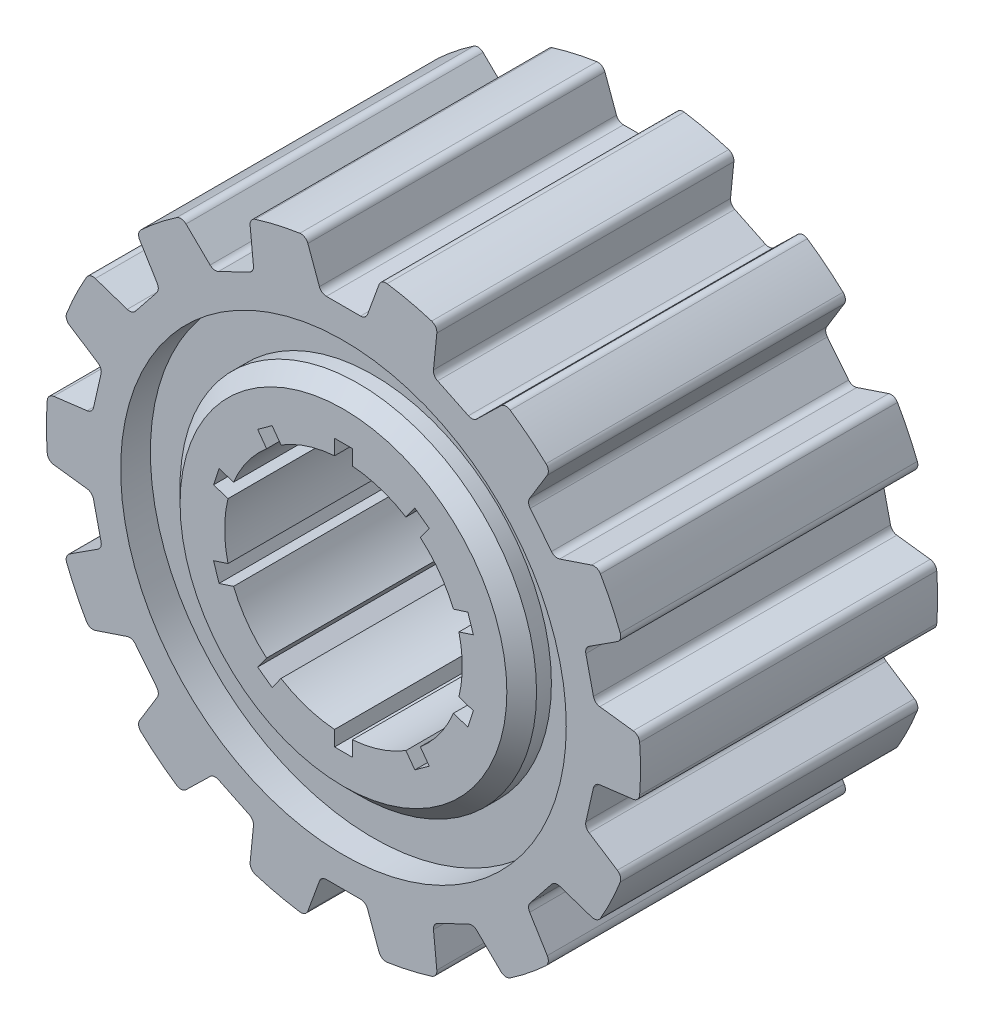
from build123d import *

# Parameters (mm, degrees)
SKETCH1_R           = 10
BOSS_EXTRUDE1_DEPTH = 10
CUT_EXTRUDE1_DEPTH  = 11
CIRPATTERN1_COUNT   = 14
CUT_EXTRUDE2_START  = -4
SKETCH3_R           = 7.5
SKETCH3_R_2         = 6
CUT_EXTRUDE2_DEPTH  = 2
CHAMFER1_SIZE       = 0.5
CHAMFER2_SIZE       = 0.5
FILLET1_R           = 0.25


with BuildPart() as part:
    # Sketch1 → Boss-Extrude1 (new body)
    with BuildSketch(Plane.XY):
        Circle(SKETCH1_R)
        with BuildLine():
            Line((2.402328537, 3.81691205), (2.887738734, 3.464240899))
            Line((2.887738734, 3.464240899), (2.587224198, 3.050618126))
            ThreePointArc((2.587224198, 3.050618126), (3.236067977, 2.351141009), (3.700806493, 1.517903589))
            Line((3.700806493, 1.517903589), (4.187049225, 1.67589343))
            Line((4.187049225, 1.67589343), (4.372459422, 1.10525952))
            Line((4.372459422, 1.10525952), (3.886216689, 0.947269679))
            ThreePointArc((3.886216689, 0.947269679), (4, 0), (3.886216689, -0.947269679))
            Line((3.886216689, -0.947269679), (4.372459422, -1.10525952))
            Line((4.372459422, -1.10525952), (4.187049225, -1.67589343))
            Line((4.187049225, -1.67589343), (3.700806493, -1.517903589))
            ThreePointArc((3.700806493, -1.517903589), (3.236067977, -2.351141009), (2.587224198, -3.050618126))
            Line((2.587224198, -3.050618126), (2.887738734, -3.464240899))
            Line((2.887738734, -3.464240899), (2.402328537, -3.81691205))
            Line((2.402328537, -3.81691205), (2.101814002, -3.403289277))
            ThreePointArc((2.101814002, -3.403289277), (1.236067977, -3.804226065), (0.3, -3.988734135))
            Line((0.3, -3.988734135), (0.3, -4.5))
            Line((0.3, -4.5), (-0.3, -4.5))
            Line((-0.3, -4.5), (-0.3, -3.988734135))
            ThreePointArc((-0.3, -3.988734135), (-1.236067977, -3.804226065), (-2.101814002, -3.403289277))
            Line((-2.101814002, -3.403289277), (-2.402328537, -3.81691205))
            Line((-2.402328537, -3.81691205), (-2.887738734, -3.464240899))
            Line((-2.887738734, -3.464240899), (-2.587224198, -3.050618126))
            ThreePointArc((-2.587224198, -3.050618126), (-3.236067977, -2.351141009), (-3.700806493, -1.517903589))
            Line((-3.700806493, -1.517903589), (-4.187049225, -1.67589343))
            Line((-4.187049225, -1.67589343), (-4.372459422, -1.10525952))
            Line((-4.372459422, -1.10525952), (-3.886216689, -0.947269679))
            ThreePointArc((-3.886216689, -0.947269679), (-4, 0), (-3.886216689, 0.947269679))
            Line((-3.886216689, 0.947269679), (-4.372459422, 1.10525952))
            Line((-4.372459422, 1.10525952), (-4.187049225, 1.67589343))
            Line((-4.187049225, 1.67589343), (-3.700806493, 1.517903589))
            ThreePointArc((-3.700806493, 1.517903589), (-3.236067977, 2.351141009), (-2.587224198, 3.050618126))
            Line((-2.587224198, 3.050618126), (-2.887738734, 3.464240899))
            Line((-2.887738734, 3.464240899), (-2.402328537, 3.81691205))
            Line((-2.402328537, 3.81691205), (-2.101814002, 3.403289277))
            ThreePointArc((-2.101814002, 3.403289277), (-1.236067977, 3.804226065), (-0.3, 3.988734135))
            Line((-0.3, 3.988734135), (-0.3, 4.5))
            Line((-0.3, 4.5), (0.3, 4.5))
            Line((0.3, 4.5), (0.3, 3.988734135))
            ThreePointArc((0.3, 3.988734135), (1.236067977, 3.804226065), (2.101814002, 3.403289277))
            Line((2.101814002, 3.403289277), (2.402328537, 3.81691205))
        make_face(mode=Mode.SUBTRACT)
    extrude(amount=BOSS_EXTRUDE1_DEPTH)

    # Sketch2 → Cut-Extrude1 (cut, through all)
    with BuildSketch(Plane.XY.offset(10)):
        Polygon((-20.341084154, 62.326061337), (-1.266640021, 9.919456792), (-0.75, 8.5), (0.75, 8.5), (1.266640021, 9.919456792), (20.341084154, 62.326061337), (20.341084154, 173.86594871), (-20.341084154, 173.86594871), align=None)
    cut_extrude1 = extrude(amount=-CUT_EXTRUDE1_DEPTH, mode=Mode.SUBTRACT)

    # CirPattern1: Cut-Extrude1 ×14 about axis
    cirpattern1_axis = Axis((0, 0, 0), (0, 0, 1))
    for i in range(1, CIRPATTERN1_COUNT):
        add(cut_extrude1.rotate(cirpattern1_axis, i * 360 / CIRPATTERN1_COUNT), mode=Mode.SUBTRACT)

    # Sketch3 → Cut-Extrude2 (cut, through all)
    with BuildSketch(Plane.XY.offset(5).offset(CUT_EXTRUDE2_START)):
        Circle(SKETCH3_R)
        Circle(SKETCH3_R_2, mode=Mode.SUBTRACT)
    cut_extrude2 = extrude(amount=-CUT_EXTRUDE2_DEPTH, mode=Mode.SUBTRACT)

    # Chamfer1
    chamfer1_edges = [part.edges().sort_by_distance(p)[0] for p in [
        (-6, 0, 0),
    ]]
    chamfer(chamfer1_edges, length=CHAMFER1_SIZE)

    # Mirror2: Cut-Extrude2 across plane
    add(cut_extrude2.mirror(Plane.XY.offset(5)), mode=Mode.SUBTRACT)

    # Chamfer2
    chamfer2_edges = [part.edges().sort_by_distance(p)[0] for p in [
        (-6, 0, 10),
    ]]
    chamfer(chamfer2_edges, length=CHAMFER2_SIZE)

    # Fillet1
    fillet1_edges = [part.edges().sort_by_distance(p)[0] for p in [
        (0.75, 8.5, 5),
        (-0.75, 8.5, 5),
        (-1.266640021, 9.919456792, 5),
        (1.266640021, 9.919456792, 5),
        (-6.17795025, 5.886036928, 5),
        (-7.113184952, 4.713289704, 5),
        (-8.545080745, 5.194381104, 5),
        (-6.965606473, 7.174979196, 5),
        (-8.119996553, 2.622623873, 5),
        (-8.453777954, 1.160232004, 5),
        (-9.952609221, 0.972404078, 5),
        (-9.38890138, 3.442169501, 5),
        (-8.453777954, -1.160232004, 5),
        (-8.119996553, -2.622623873, 5),
        (-9.38890138, -3.442169501, 5),
        (-9.952609221, -0.972404078, 5),
        (-7.113184952, -4.713289704, 5),
        (-6.17795025, -5.886036928, 5),
        (-6.965606473, -7.174979196, 5),
        (-8.545080745, -5.194381104, 5),
        (-4.363738433, -7.332822573, 5),
        (-3.012285132, -7.983648182, 5),
        (-3.162687777, -9.486696265, 5),
        (-5.445094229, -8.387547248, 5),
        (-0.75, -8.5, 5),
        (0.75, -8.5, 5),
        (1.266640021, -9.919456792, 5),
        (-1.266640021, -9.919456792, 5),
        (3.012285132, -7.983648182, 5),
        (4.363738433, -7.332822573, 5),
        (5.445094229, -8.387547248, 5),
        (3.162687777, -9.486696265, 5),
        (6.17795025, -5.886036928, 5),
        (7.113184952, -4.713289704, 5),
        (8.545080745, -5.194381104, 5),
        (6.965606473, -7.174979196, 5),
        (8.119996553, -2.622623873, 5),
        (8.453777954, -1.160232004, 5),
        (9.952609221, -0.972404078, 5),
        (9.38890138, -3.442169501, 5),
        (8.453777954, 1.160232004, 5),
        (8.119996553, 2.622623873, 5),
        (9.38890138, 3.442169501, 5),
        (9.952609221, 0.972404078, 5),
        (7.113184952, 4.713289704, 5),
        (6.17795025, 5.886036928, 5),
        (6.965606473, 7.174979196, 5),
        (8.545080745, 5.194381104, 5),
        (4.363738433, 7.332822573, 5),
        (3.012285132, 7.983648182, 5),
        (3.162687777, 9.486696265, 5),
        (5.445094229, 8.387547248, 5),
        (-3.012285132, 7.983648182, 5),
        (-4.363738433, 7.332822573, 5),
        (-5.445094229, 8.387547248, 5),
        (-3.162687777, 9.486696265, 5),
    ]]
    fillet(fillet1_edges, radius=FILLET1_R)


solid = part.part
